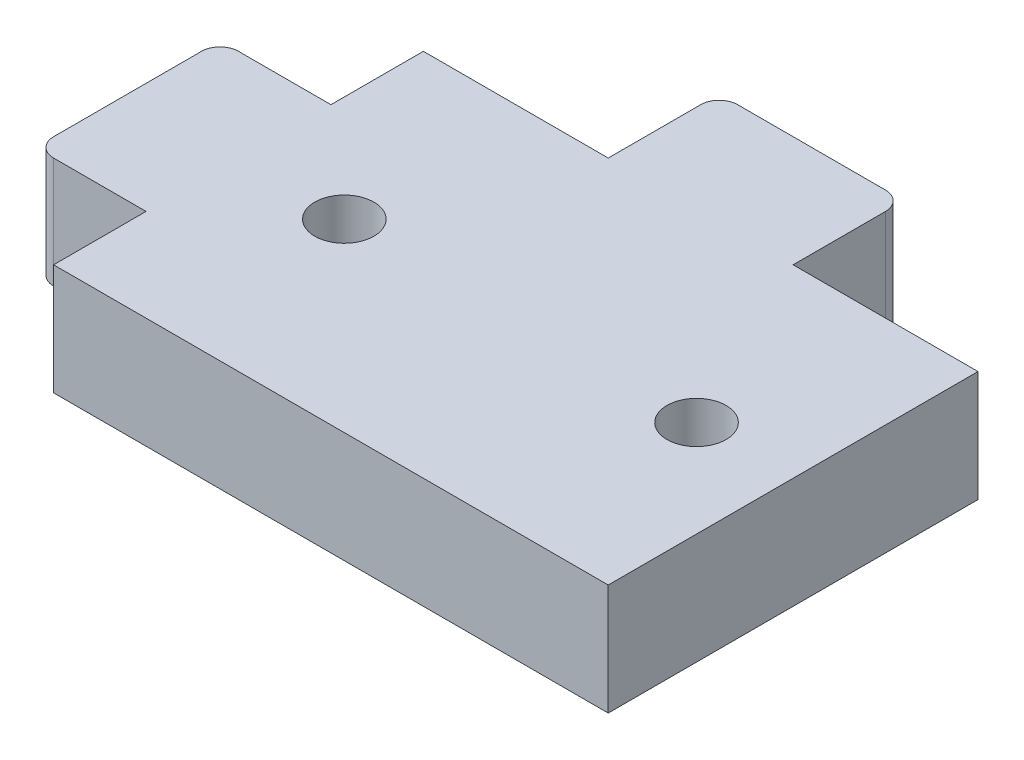
from build123d import *

# Parameters (mm, degrees)
SKETCH1_W              = 30
SKETCH1_H              = 20
BOSS_EXTRUDE1_DEPTH    = 6
M3_CLEARANCE_HOLE1_D   = 3.2
SKETCH234_W            = 10
SKETCH234_H            = 6
BOSS_EXTRUDE234_DEPTH  = 6
FILLET134_R            = 1
SKETCH2342_W           = 10
SKETCH2342_H           = 6
BOSS_EXTRUDE2342_DEPTH = 6
FILLET1342_R           = 1


with BuildPart() as part:
    # Sketch1 → Boss-Extrude1 (new body)
    with BuildSketch(Plane(origin=(0, 0, 0), x_dir=(1, 0, 0), z_dir=(0, 1, 0))):
        Rectangle(SKETCH1_W, SKETCH1_H)
    extrude(amount=BOSS_EXTRUDE1_DEPTH)

    # M3 Clearance Hole1 (through all)
    with Locations(Plane(origin=(0, 6, 0), x_dir=(1, 0, 0), z_dir=(0, 1, 0))):
        with Locations((-9.275, 0), (9.775, 0)):
            Hole(M3_CLEARANCE_HOLE1_D / 2)

    # Sketch234 → Boss-Extrude234 (add)
    with BuildSketch(Plane(origin=(-15, 6, 0.767778608), x_dir=(0, 0, -1), z_dir=(-1, 0, 0))):
        with Locations((0.767778608, 3)):
            Rectangle(SKETCH234_W, SKETCH234_H)
    extrude(amount=BOSS_EXTRUDE234_DEPTH)

    # Fillet134
    fillet134_edges = [part.edges().sort_by_distance(p)[0] for p in [
        (-21, 3, 5),
        (-21, 3, -5),
    ]]
    fillet(fillet134_edges, radius=FILLET134_R)

    # Sketch2342 → Boss-Extrude2342 (add)
    with BuildSketch(Plane(origin=(-0.767778608, 6, -10), x_dir=(1, 0, 0), z_dir=(0, 0, -1))):
        with Locations((0.767778608, 3)):
            Rectangle(SKETCH2342_W, SKETCH2342_H)
    extrude(amount=BOSS_EXTRUDE2342_DEPTH)

    # Fillet1342
    fillet1342_edges = [part.edges().sort_by_distance(p)[0] for p in [
        (-5, 3, -16),
        (5, 3, -16),
    ]]
    fillet(fillet1342_edges, radius=FILLET1342_R)


solid = part.part
